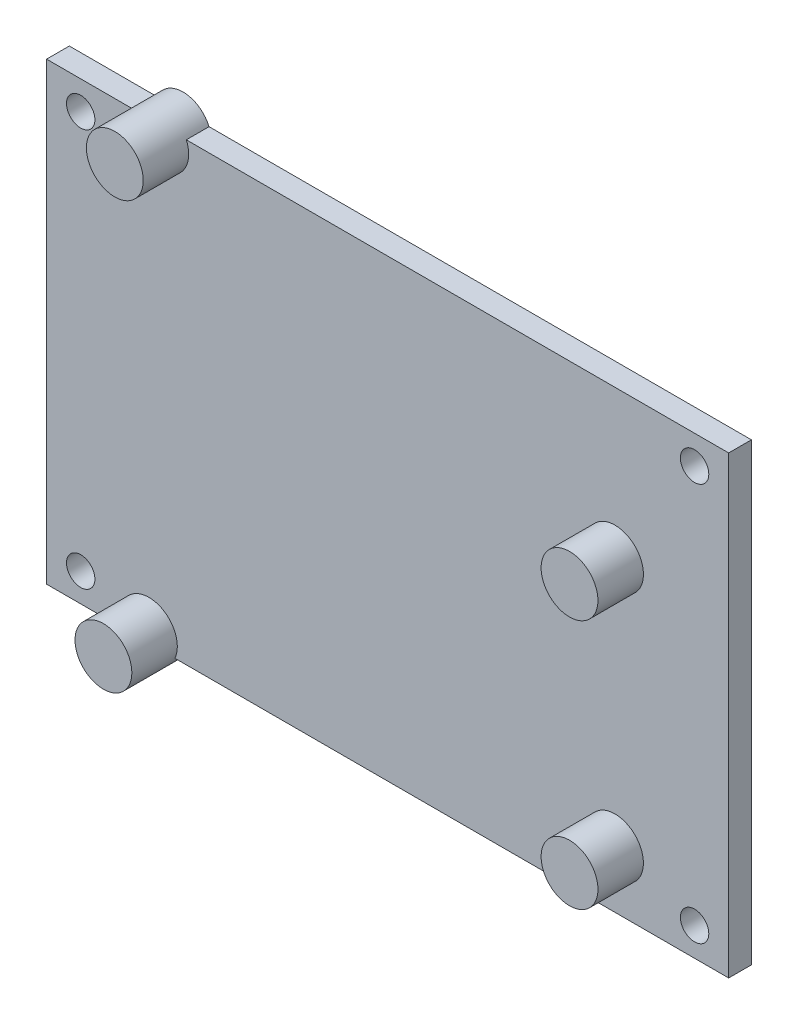
from build123d import *

# Parameters (mm, degrees)
SKETCH1_W                = 76.2
SKETCH1_H                = 50.8
SKETCH1_R                = 1.5875
BOSS_EXTRUDE1_DEPTH      = 2.54
SKETCH2_R                = 3.175
BOSS_EXTRUDE2_DEPTH      = 5.08
BOSS_EXTRUDE2_DEPTH_BACK = 2.54


with BuildPart() as part:
    # Sketch1 → Boss-Extrude1 (new body)
    with BuildSketch(Plane.XY):
        Rectangle(SKETCH1_W, SKETCH1_H)
        with Locations((-34.29, 22.225)):
            Circle(SKETCH1_R, mode=Mode.SUBTRACT)
        with Locations((34.29, 22.225)):
            Circle(SKETCH1_R, mode=Mode.SUBTRACT)
        with Locations((34.29, -22.225)):
            Circle(SKETCH1_R, mode=Mode.SUBTRACT)
        with Locations((-34.29, -22.225)):
            Circle(SKETCH1_R, mode=Mode.SUBTRACT)
    extrude(amount=BOSS_EXTRUDE1_DEPTH)

    # Sketch2 → Boss-Extrude2 (add, two sides)
    with BuildSketch(Plane.XY.offset(2.54)) as boss_extrude2_sk:
        with Locations((-25.4, 24.13)):
            Circle(SKETCH2_R)
        with Locations((-26.67, -24.13)):
            Circle(SKETCH2_R)
        with Locations((25.4, 8.89)):
            Circle(SKETCH2_R)
        with Locations((25.4, -19.05)):
            Circle(SKETCH2_R)
    extrude(amount=BOSS_EXTRUDE2_DEPTH)
    extrude(boss_extrude2_sk.sketch, amount=-BOSS_EXTRUDE2_DEPTH_BACK)


solid = part.part
